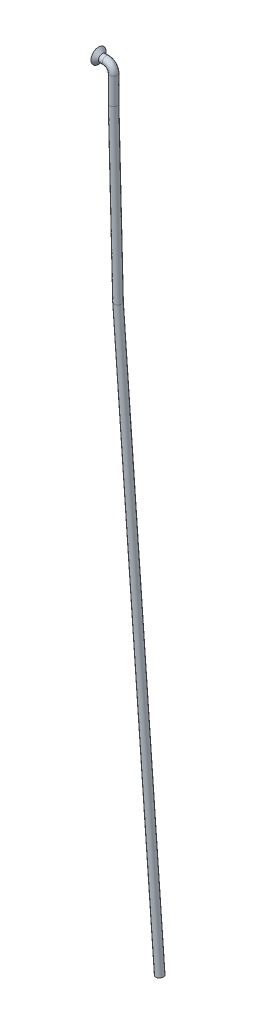
from build123d import *

# Parameters (mm, degrees)
ESQUISSE2_R = 1


with BuildPart() as part:
    # Balayage1: sweep along a path in Esquisse1
    with BuildLine(Plane.XY) as balayage1_path:
        Line((12.227962674, -203.032108123), (1.177962674, -53.984579624))
        Line((1.177962674, -53.984579624), (0, -9))
        Line((0, -9), (0, -2))
        ThreePointArc((0, -2), (-0.585786438, -0.585786438), (-2, 0))
        Line((-2, 0), (-4, 0))
    # Esquisse2 → Balayage1 (sweep)
    with BuildSketch(Plane(origin=(-4, 0, 0), x_dir=(0, 0, -1), z_dir=(1, 0, 0))):
        Circle(ESQUISSE2_R)
    sweep(path=balayage1_path.line, transition=Transition.RIGHT)

    # Esquisse3 → Révolution1 (revolve)
    with BuildSketch(Plane.XY):
        Polygon((-4, 1), (-4, 2), (-3, 1), align=None)
    revolve(axis=Axis((0, 0, 0), (-1, 0, 0)))


solid = part.part
